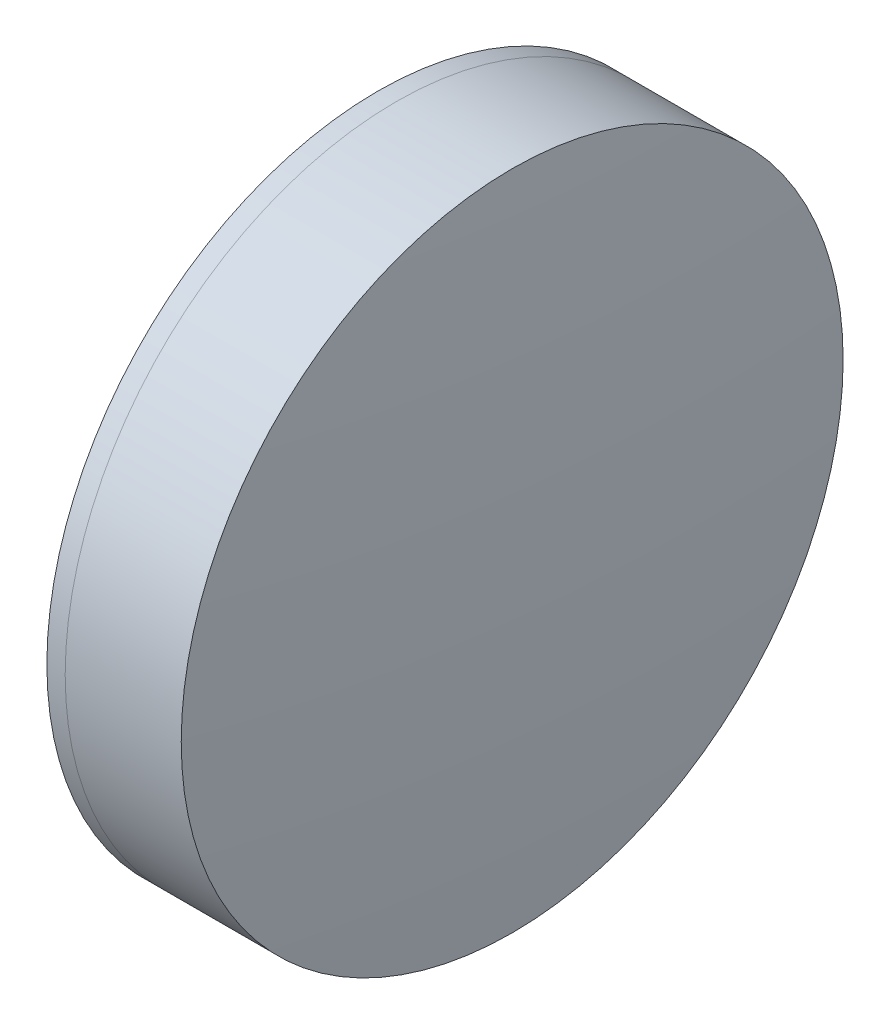
from build123d import *


with BuildPart() as part:
    # 草图1 one side → 旋转1 (revolve)
    with BuildSketch(Plane(origin=(0, 0, 0), x_dir=(1, 0, 0), z_dir=(0, 1, 0)), mode=Mode.PRIVATE) as revolve_1_sk:
        with BuildLine():
            ThreePointArc((521.413337107, 25.4), (516.44977384, 13.128668078), (514.758436509, 0))
            Line((514.758436509, 0), (530.758436509, 0))
            ThreePointArc((530.758436509, 0), (528.727339525, 13.305957163), (522.819042069, 25.4))
            Line((522.819042069, 25.4), (521.413337107, 25.4))
        make_face()
    revolve(revolve_1_sk.sketch.rotate(Axis((124.523309526, 0, 0), (1, 0, 0)), 180), axis=Axis((124.523309526, 0, 0), (1, 0, 0)))  # turned: the seam where the file's is


with BuildPart() as body_2:
    # 草图2 one side → 旋转3 (revolve)
    with BuildSketch(Plane(origin=(0, 0, 0), x_dir=(1, 0, 0), z_dir=(0, 1, 0)), mode=Mode.PRIVATE) as revolve_3_sk:
        with BuildLine():
            Line((531.724801831, 25.4), (522.819042069, 25.4))
            ThreePointArc((522.819042069, 25.4), (528.727339525, 13.305957163), (530.758436509, 0))
            Line((530.758436509, 0), (532.758436509, 0))
            ThreePointArc((532.758436509, 0), (532.499920945, 12.710511404), (531.724801831, 25.4))
        make_face()
    revolve(revolve_3_sk.sketch.rotate(Axis((-0.551919993, 0, 0), (1, 0, 0)), 180), axis=Axis((-0.551919993, 0, 0), (1, 0, 0)))  # turned: the seam where the file's is


solid = Compound([part.part, body_2.part])
